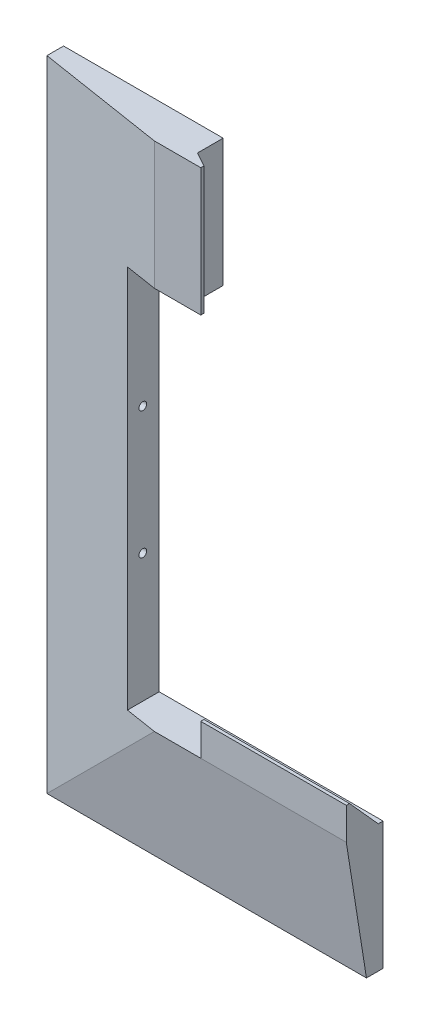
from build123d import *

# Parameters (mm, degrees)
DODANIE_WYCI_GNI_CIE1_DEPTH = 5.2
SZKIC3_W                    = 60
SZKIC3_H                    = 159.9
SZKIC5_W                    = 99.9
SZKIC5_H                    = 199.8
SZKIC6_W                    = 49.271239353
SZKIC6_H                    = 120
WYTNIJ_WYCI_GNI_CIE1_DEPTH  = 78
WYTNIJ_WYCI_GNI_CIE2_DEPTH  = 5.6
SZKIC9_R                    = 2.424871131
SZKIC9_R_2                  = 1.2
DODANIE_WYCI_GNI_CIE3_DEPTH = 3.8
SZKIC10_W                   = 50
SZKIC10_H                   = 39.9
WYTNIJ_WYCI_GNI_CIE4_DEPTH  = 24
DODANIE_WYCI_GNI_CIE4_DEPTH = 39.9
DODANIE_WYCI_GNI_CIE5_DEPTH = 45.5


with BuildPart() as part:
    # Szkic2 → Dodanie-wyciągnięcie1 (new body)
    with BuildSketch(Plane.XY):
        Polygon((18.542832418, 83.245366469), (18.542832418, 43.345366469), (-51.457167582, 43.345366469), (-51.457167582, -76.654633531), (18.542832418, -76.654633531), (18.542832418, -116.554633531), (-81.357167582, -116.554633531), (-81.357167582, 83.245366469), align=None)
    extrude(amount=DODANIE_WYCI_GNI_CIE1_DEPTH)

    # Szkic3 → Wyciągnięcie po profilach3 section 0
    with BuildSketch(Plane.XY.offset(11.5)):
        with Locations((-11.457167582, 3.295366469)):
            Rectangle(SZKIC3_W, SZKIC3_H)
    # Szkic5 → Wyciągnięcie po profilach3 section 1
    with BuildSketch(Plane.XY.offset(5.2)):
        with Locations((-31.407167582, -16.654633531)):
            Rectangle(SZKIC5_W, SZKIC5_H)
    loft()

    # Szkic6 → Wytnij-wyciągnięcie1 (cut)
    with BuildSketch(Plane(origin=(-51.457167582, 0, 0), x_dir=(0, 0, -1), z_dir=(1, 0, 0))):
        with Locations((-24.635619677, -16.654633531)):
            Rectangle(SZKIC6_W, SZKIC6_H)
    extrude(amount=WYTNIJ_WYCI_GNI_CIE1_DEPTH, mode=Mode.SUBTRACT)

    # Szkic7 → Wytnij-wyciągnięcie2 (cut)
    with BuildSketch(Plane(origin=(-51.457167582, 0, 0), x_dir=(0, 0, -1), z_dir=(1, 0, 0))):
        Polygon((-5.12, -34.1297624), (-7.22, -35.342197966), (-7.22, -37.767069096), (-5.12, -38.979504662), (-3.02, -37.767069096), (-3.02, -35.342197966), align=None)
        Polygon((-5.12, 5.6702376), (-7.22, 4.457802034), (-7.22, 2.032930904), (-5.12, 0.820495338), (-3.02, 2.032930904), (-3.02, 4.457802034), align=None)
    extrude(amount=-WYTNIJ_WYCI_GNI_CIE2_DEPTH, mode=Mode.SUBTRACT)

    # Szkic9 → Dodanie-wyciągnięcie3 (add)
    with BuildSketch(Plane(origin=(-51.457167582, 0, 0), x_dir=(0, 0, -1), z_dir=(1, 0, 0))):
        with Locations((-5.12, 3.245366469)):
            Circle(SZKIC9_R)
        with Locations((-5.12, 3.245366469)):
            Circle(SZKIC9_R_2, mode=Mode.SUBTRACT)
        with Locations((-5.12, -36.554633531)):
            Circle(SZKIC9_R)
        with Locations((-5.12, -36.554633531)):
            Circle(SZKIC9_R_2, mode=Mode.SUBTRACT)
    extrude(amount=-DODANIE_WYCI_GNI_CIE3_DEPTH)

    # Szkic10 → Wytnij-wyciągnięcie4 (cut)
    with BuildSketch(Plane.XY.offset(11.5)):
        with Locations((-6.457167582, 63.295366469)):
            Rectangle(SZKIC10_W, SZKIC10_H)
    extrude(amount=-WYTNIJ_WYCI_GNI_CIE4_DEPTH, mode=Mode.SUBTRACT)

    # Szkic12 → Dodanie-wyciągnięcie4 (add)
    with BuildSketch(Plane(origin=(0, 83.245366469, 0), x_dir=(1, 0, 0), z_dir=(0, 1, 0))):
        Polygon((-31.457167582, -11.5), (-26.957167582, -11.5), (-26.957167582, -10.5), (-31.457167582, -8), align=None)
    extrude(amount=-DODANIE_WYCI_GNI_CIE4_DEPTH)

    # Szkic13 → Dodanie-wyciągnięcie5 (add)
    with BuildSketch(Plane(origin=(18.542832418, 0, 0), x_dir=(0, 0, -1), z_dir=(1, 0, 0))):
        Polygon((-11.5, -76.654633531), (-1.5, -76.654633531), (-10.5, -66.654633531), (-11.5, -66.654633531), align=None)
    extrude(amount=-DODANIE_WYCI_GNI_CIE5_DEPTH)


solid = part.part
